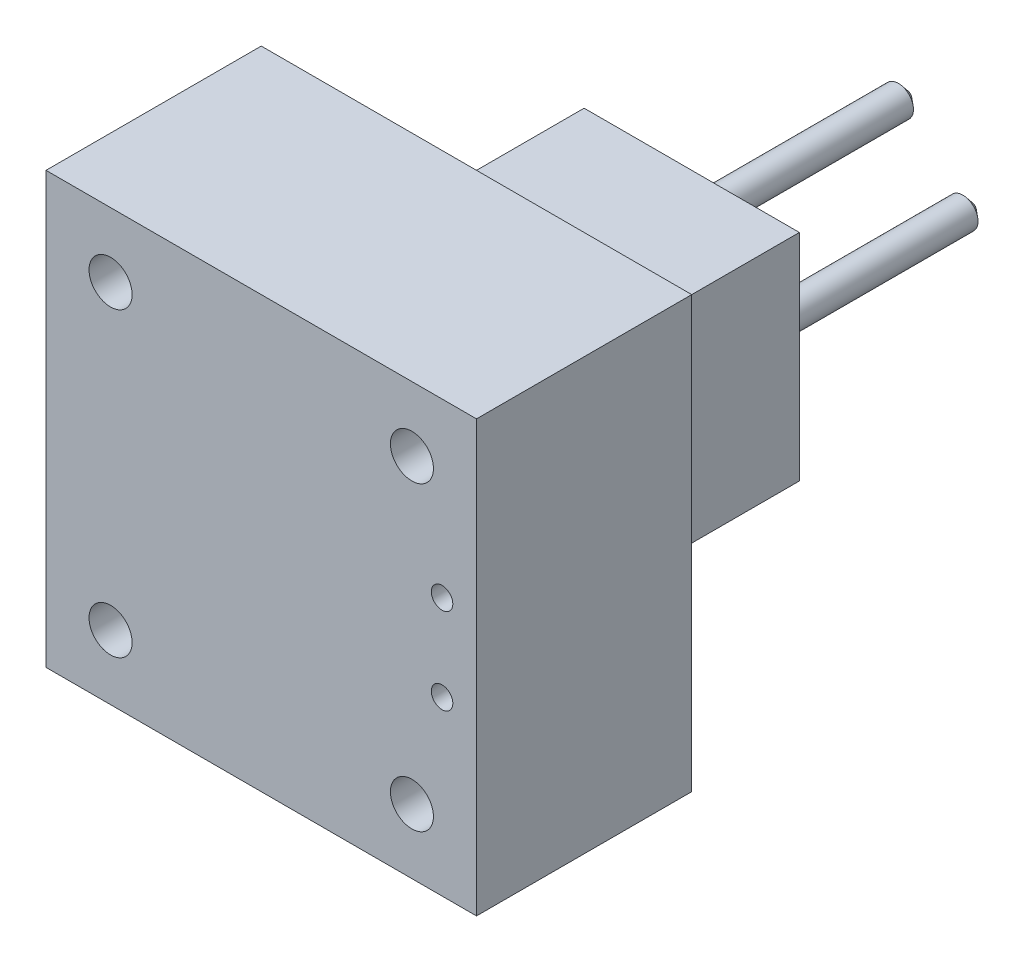
from build123d import *

# Parameters (mm, degrees)
SKETCH_1_W             = 100
SKETCH_1_H             = 100
EXTRUDE_1_DEPTH        = 50
SKETCH_2_R             = 5
CUT_EXTRUDE_1_DEPTH    = 51
SKETCH_4_R             = 2.5
CUT_EXTRUDE_2_DEPTH    = 51
SKETCH_5_W             = 50
SKETCH_5_H             = 50
EXTRUDE_3_DEPTH        = 50
SKETCH_3_R             = 3.5
EXTRUDE_4_DEPTH        = 100
CHAMFER_4_SIZE         = 2
CHAMFER_4_SIZE2        = 2.383507185
CHAMFER_4_PART_2_SIZE  = 2
CHAMFER_4_PART_2_SIZE2 = 2.383507185
CHAMFER_4_PART_3_SIZE  = 2
CHAMFER_4_PART_3_SIZE2 = 2.383507185
CHAMFER_4_PART_4_SIZE  = 2
CHAMFER_4_PART_4_SIZE2 = 2.383507185


with BuildPart() as part:
    # 草图1 → 凸台-拉伸1 (new body)
    with BuildSketch(Plane.XY):
        with Locations((3.968253968, -18.783068783)):
            Rectangle(SKETCH_1_W, SKETCH_1_H)
    extrude(amount=EXTRUDE_1_DEPTH)

    # 草图2 → 切除-拉伸1 (cut, through all)
    with BuildSketch(Plane(origin=(0, 0, 0), x_dir=(-1, 0, 0), z_dir=(0, 0, -1))):
        with Locations((-38.968253968, 16.216931217)):
            Circle(SKETCH_2_R)
        with Locations((31.031746032, 16.216931217)):
            Circle(SKETCH_2_R)
        with Locations((-38.968253968, -53.783068783)):
            Circle(SKETCH_2_R)
        with Locations((31.031746032, -53.783068783)):
            Circle(SKETCH_2_R)
    extrude(amount=-CUT_EXTRUDE_1_DEPTH, mode=Mode.SUBTRACT)

    # 草图4 → 切除-拉伸2 (cut, through all)
    with BuildSketch(Plane(origin=(0, 0, 0), x_dir=(-1, 0, 0), z_dir=(0, 0, -1))):
        with Locations((-45.968253968, -8.783068783)):
            Circle(SKETCH_4_R)
        with Locations((-45.968253968, -28.783068783)):
            Circle(SKETCH_4_R)
    extrude(amount=-CUT_EXTRUDE_2_DEPTH, mode=Mode.SUBTRACT)

    # 草图5 → 凸台-拉伸3 (add)
    with BuildSketch(Plane(origin=(0, 0, 0), x_dir=(-1, 0, 0), z_dir=(0, 0, -1))):
        with Locations((-3.968253968, -18.783068783)):
            Rectangle(SKETCH_5_W, SKETCH_5_H)
    extrude(amount=EXTRUDE_3_DEPTH)

    # 草图3 → 凸台-拉伸4 (add)
    with BuildSketch(Plane(origin=(0, 0, 0), x_dir=(-1, 0, 0), z_dir=(0, 0, -1))):
        with Locations((-3.968253968, -3.783068783)):
            Circle(SKETCH_3_R)
        with Locations((-18.968253968, -18.783068783)):
            Circle(SKETCH_3_R)
        with Locations((-3.968253968, -33.783068783)):
            Circle(SKETCH_3_R)
        with Locations((11.031746032, -18.783068783)):
            Circle(SKETCH_3_R)
    extrude(amount=EXTRUDE_4_DEPTH)

    # 倒角4
    chamfer_4_edges = [part.edges().sort_by_distance(p)[0] for p in [
        (7.468253968, -3.783068783, -100),
    ]]
    chamfer_4_side = [part.faces().sort_by_distance(p)[0] for p in [
        (7.468253968, -3.783068783, -75),
    ]]
    chamfer(chamfer_4_edges, length=CHAMFER_4_SIZE, length2=CHAMFER_4_SIZE2, reference=chamfer_4_side[0])

    # 倒角4 part 2
    chamfer_4_part_2_edges = [part.edges().sort_by_distance(p)[0] for p in [
        (22.468253968, -18.783068783, -100),
    ]]
    chamfer_4_part_2_side = [part.faces().sort_by_distance(p)[0] for p in [
        (22.468253968, -18.783068783, -75),
    ]]
    chamfer(chamfer_4_part_2_edges, length=CHAMFER_4_PART_2_SIZE, length2=CHAMFER_4_PART_2_SIZE2, reference=chamfer_4_part_2_side[0])

    # 倒角4 part 3
    chamfer_4_part_3_edges = [part.edges().sort_by_distance(p)[0] for p in [
        (7.468253968, -33.783068783, -100),
    ]]
    chamfer_4_part_3_side = [part.faces().sort_by_distance(p)[0] for p in [
        (7.468253968, -33.783068783, -75),
    ]]
    chamfer(chamfer_4_part_3_edges, length=CHAMFER_4_PART_3_SIZE, length2=CHAMFER_4_PART_3_SIZE2, reference=chamfer_4_part_3_side[0])

    # 倒角4 part 4
    chamfer_4_part_4_edges = [part.edges().sort_by_distance(p)[0] for p in [
        (-7.531746032, -18.783068783, -100),
    ]]
    chamfer_4_part_4_side = [part.faces().sort_by_distance(p)[0] for p in [
        (-7.531746032, -18.783068783, -75),
    ]]
    chamfer(chamfer_4_part_4_edges, length=CHAMFER_4_PART_4_SIZE, length2=CHAMFER_4_PART_4_SIZE2, reference=chamfer_4_part_4_side[0])


solid = part.part
